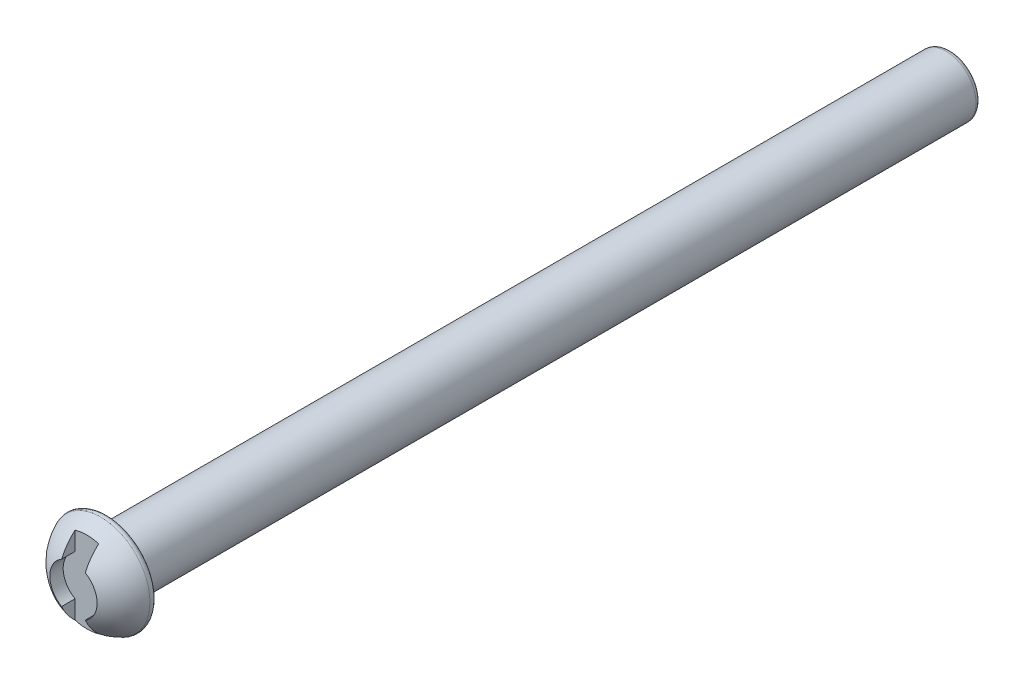
from build123d import *

# Parameters (mm, degrees)
FILLET1_R          = 0.75
CUT_EXTRUDE6_DEPTH = 3


with BuildPart() as part:
    # Sketch1 → Revolve1 (revolve)
    with BuildSketch(Plane(origin=(0, 0, 0), x_dir=(0, 0, -1), z_dir=(1, 0, 0))):
        with BuildLine():
            Line((0, 0), (140, 0))
            Line((140, 0), (140, 4.75))
            Line((140, 4.75), (6.25, 4.75))
            Line((6.25, 4.75), (6.25, 8.15))
            ThreePointArc((6.25, 8.15), (1.742375921, 5.135294539), (0, 0))
        make_face()
    revolve(axis=Axis((0, 0, 0), (0, 0, -1)))

    # Fillet1
    fillet1_edges = [part.edges().sort_by_distance(p)[0] for p in [
        (0, -8.15, -6.25),
        (0, -4.75, -140),
    ]]
    fillet(fillet1_edges, radius=FILLET1_R)

    # Sketch4 → Cut-Extrude6 (cut)
    with BuildSketch(Plane.XY):
        with BuildLine():
            Line((1.875, -3.247595264), (1.875, -9.329244328))
            Line((1.875, -9.329244328), (-1.875, -9.329244328))
            Line((-1.875, -9.329244328), (-1.875, -3.247595264))
            ThreePointArc((-1.875, -3.247595264), (-3.75, 0), (-1.875, 3.247595264))
            Line((-1.875, 3.247595264), (-1.875, 9.329244328))
            Line((-1.875, 9.329244328), (1.875, 9.329244328))
            Line((1.875, 9.329244328), (1.875, 3.247595264))
            ThreePointArc((1.875, 3.247595264), (3.75, 0), (1.875, -3.247595264))
        make_face()
    extrude(amount=-CUT_EXTRUDE6_DEPTH, mode=Mode.SUBTRACT)


solid = part.part
